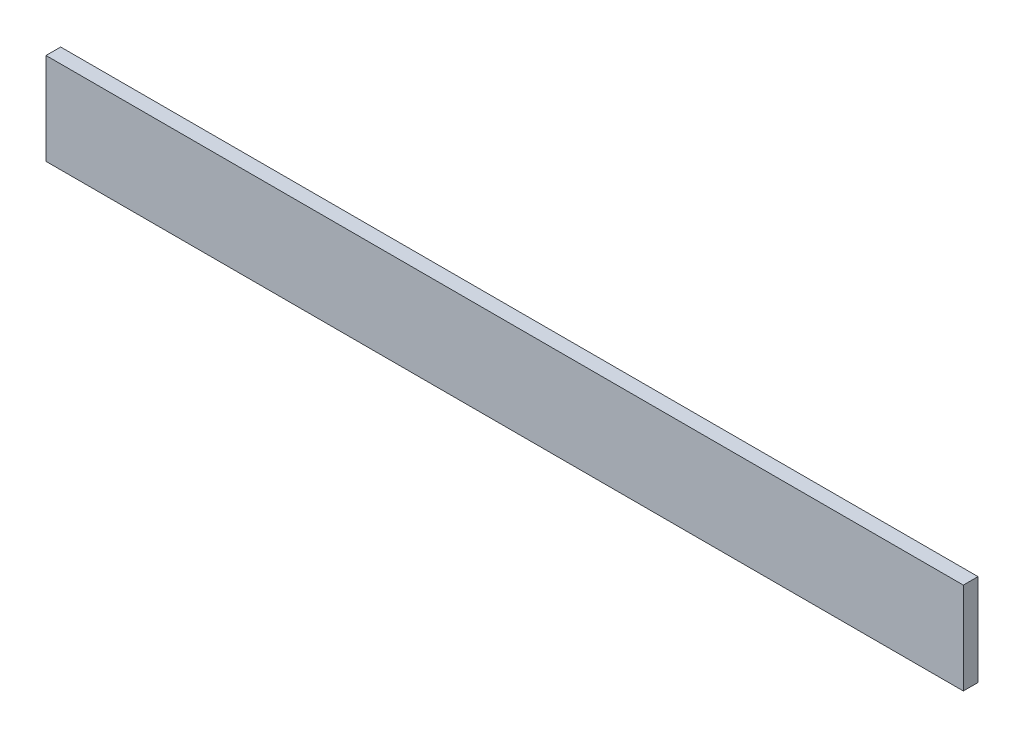
from build123d import *

# Parameters (mm, degrees)
SKETCH1_W           = 190.5
SKETCH1_H           = 19.05
BOSS_EXTRUDE1_DEPTH = 3.048


with BuildPart() as part:
    # Sketch1 → Boss-Extrude1 (new body)
    with BuildSketch(Plane.XY):
        with Locations((0, 9.525)):
            Rectangle(SKETCH1_W, SKETCH1_H)
    extrude(amount=BOSS_EXTRUDE1_DEPTH)


solid = part.part
